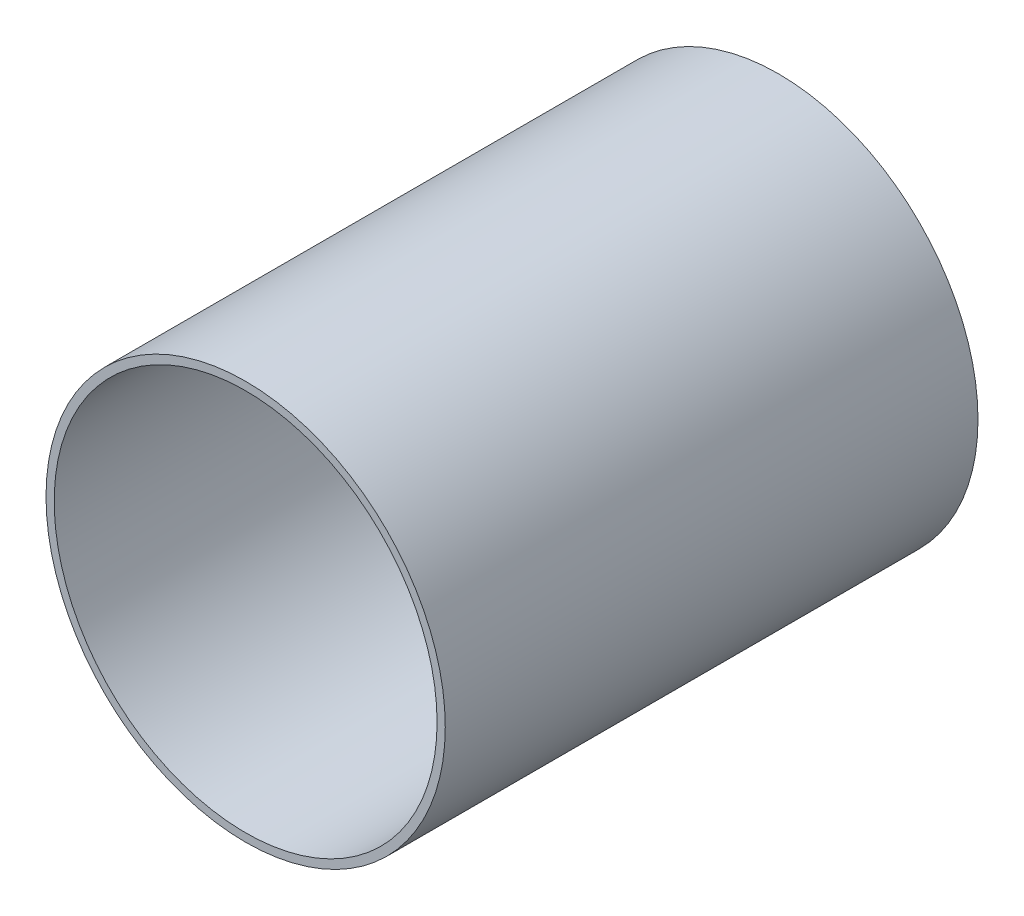
from build123d import *

# Parameters (mm, degrees)
SKETCH1_R           = 38.0746
SKETCH1_R_2         = 36.5125
BOSS_EXTRUDE1_DEPTH = 50.8


with BuildPart() as part:
    # Sketch1 → Boss-Extrude1 (new body, symmetric)
    with BuildSketch(Plane.XY):
        Circle(SKETCH1_R)
        Circle(SKETCH1_R_2, mode=Mode.SUBTRACT)
    extrude(amount=BOSS_EXTRUDE1_DEPTH, both=True)


solid = part.part
